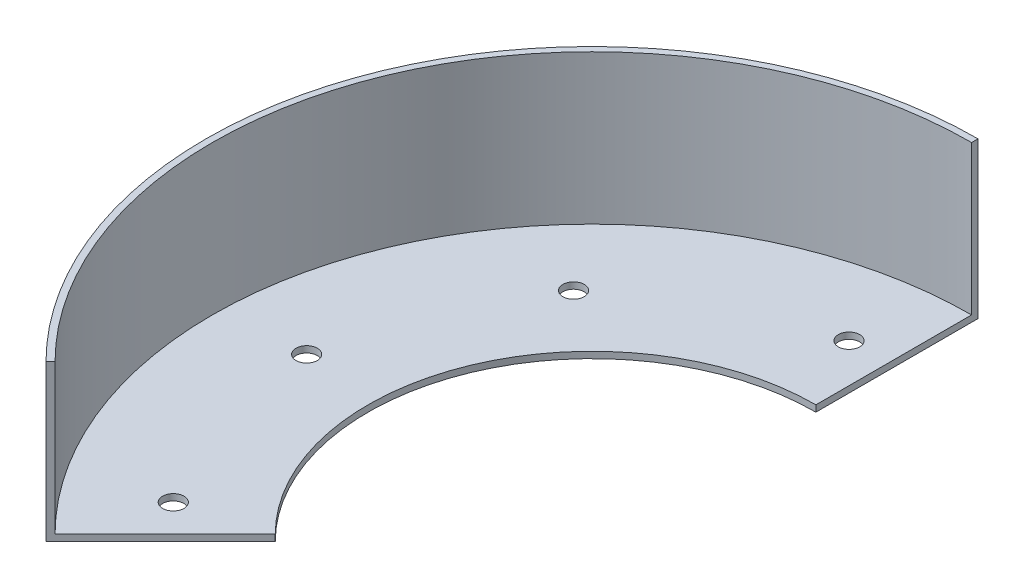
from build123d import *

# Parameters (mm, degrees)
BOSS_EXTRUDE3_DEPTH = 3
BOSS_EXTRUDE4_DEPTH = 70
SKETCH6_R           = 5
CUT_EXTRUDE2_DEPTH  = 10


with BuildPart() as part:
    # Sketch1 → Boss-Extrude3 (new body)
    with BuildSketch(Plane(origin=(0, 0, 0), x_dir=(1, 0, 0), z_dir=(0, 1, 0))):
        with BuildLine():
            Line((0, 105), (0, 181))
            ThreePointArc((0, 181), (-167.222195385, 69.265701258), (-127.986327395, -127.986327395))
            Line((-127.986327395, -127.986327395), (-74.246212025, -74.246212025))
            ThreePointArc((-74.246212025, -74.246212025), (-97.007350914, 40.181760398), (0, 105))
        make_face()
    extrude(amount=BOSS_EXTRUDE3_DEPTH)

    # Sketch5 → Boss-Extrude4 (add)
    with BuildSketch(Plane(origin=(0, 3, 0), x_dir=(1, 0, 0), z_dir=(0, 1, 0))):
        with BuildLine():
            Line((0, 181), (0, 178))
            ThreePointArc((0, 178), (-164.450556787, 68.117650961), (-125.865007051, -125.865007051))
            Line((-125.865007051, -125.865007051), (-127.986327395, -127.986327395))
            ThreePointArc((-127.986327395, -127.986327395), (-167.222195385, 69.265701258), (0, 181))
        make_face()
    extrude(amount=BOSS_EXTRUDE4_DEPTH)

    # Sketch6 → Cut-Extrude2 (cut)
    with BuildSketch(Plane(origin=(0, 3, 0), x_dir=(1, 0, 0), z_dir=(0, 1, 0))):
        with Locations((-139.864087078, 6.106597921)):
            Circle(SKETCH6_R)
        with Locations((-111.067352179, -85.224976811)):
            Circle(SKETCH6_R)
        with Locations((-103.216861218, 94.580827618)):
            Circle(SKETCH6_R)
        with Locations((-18.273318865, 138.799636924)):
            Circle(SKETCH6_R)
    extrude(amount=-CUT_EXTRUDE2_DEPTH, mode=Mode.SUBTRACT)


solid = part.part
